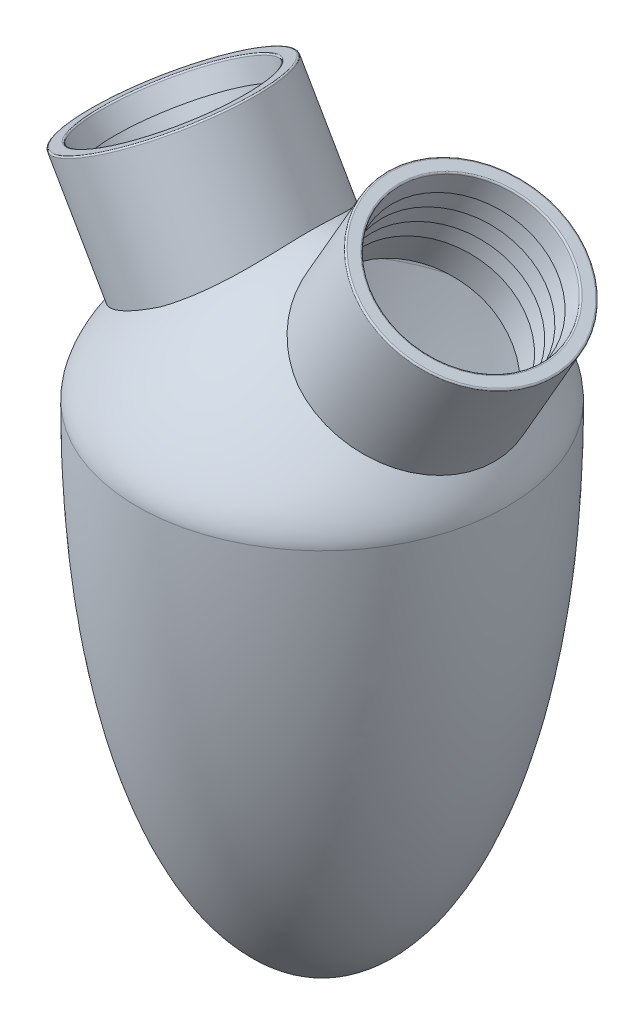
from build123d import *

# Parameters (mm, degrees)
SKETCH4_R                = 18.775
BOSS_EXTRUDE1_DEPTH      = 20
BOSS_EXTRUDE1_DEPTH_BACK = 3.5
SKETCH5_R                = 18.775
BOSS_EXTRUDE2_DEPTH      = 20
BOSS_EXTRUDE2_DEPTH_BACK = 3.5
SKETCH6_R                = 16.125
CUT_EXTRUDE1_DEPTH       = 24.3
SKETCH7_R                = 16.125
CUT_EXTRUDE2_DEPTH       = 24.3
FILLET1_R                = 0.3
LPATTERN1_COUNT          = 4
LPATTERN1_PITCH          = 4
LPATTERN2_COUNT          = 4
LPATTERN2_PITCH          = 4


with BuildPart() as part:
    # Sketch1 → Revolve1 (revolve)
    with BuildSketch(Plane.XY):
        with BuildLine():
            Line((0, 27.5), (0, 26.2))
            add(Edge.make_bspline(
                [(0, 26.2), (16.666666667, 26.2), (35, 7.333333333), (35, 0)],
                knots=[0, 0, 0, 0, 1, 1, 1, 1], degree=3))
            add(Edge.make_bspline(
                [(35, 0), (35, -62.333333333), (16.666666667, -93.4), (0, -93.4)],
                knots=[0, 0, 0, 0, 1, 1, 1, 1], degree=3))
            Line((0, -93.4), (0, -94.7))
            add(Edge.make_bspline(
                [(36.3, 0), (36.3, -63.333333333), (17.333333333, -94.7), (0, -94.7)],
                knots=[0, 0, 0, 0, 1, 1, 1, 1], degree=3))
            add(Edge.make_bspline(
                [(0, 27.5), (17, 27.5), (36.3, 7.666666667), (36.3, 0)],
                knots=[0, 0, 0, 0, 1, 1, 1, 1], degree=3))
        make_face()
    revolve(axis=Axis((0, 0, 0), (0, -1, 0)))

    # Sketch4 → Boss-Extrude1 (add, two sides)
    with BuildSketch(Plane(origin=(-12.990381057, 22.5, 0), x_dir=(0, 0, 1), z_dir=(-0.5, 0.866025404, 0))) as boss_extrude1_sk:
        with Locations((0, -7.323500512)):
            Circle(SKETCH4_R)
    extrude(amount=BOSS_EXTRUDE1_DEPTH)
    extrude(boss_extrude1_sk.sketch, amount=-BOSS_EXTRUDE1_DEPTH_BACK)

    # Sketch5 → Boss-Extrude2 (add, two sides)
    with BuildSketch(Plane(origin=(12.990381057, 22.5, 0), x_dir=(0, 0, 1), z_dir=(0.5, 0.866025404, 0))) as boss_extrude2_sk:
        with Locations((0, 7.312391534)):
            Circle(SKETCH5_R)
    extrude(amount=BOSS_EXTRUDE2_DEPTH)
    extrude(boss_extrude2_sk.sketch, amount=-BOSS_EXTRUDE2_DEPTH_BACK)

    # Sketch6 → Cut-Extrude1 (cut)
    with BuildSketch(Plane(origin=(-22.990381057, 39.820508076, 0), x_dir=(0.866025404, 0.5, 0), z_dir=(-0.5, 0.866025404, 0))):
        with Locations((-7.323500512, 0)):
            Circle(SKETCH6_R)
    extrude(amount=-CUT_EXTRUDE1_DEPTH, mode=Mode.SUBTRACT)

    # Sketch7 → Cut-Extrude2 (cut)
    with BuildSketch(Plane(origin=(22.990381057, 39.820508076, 0), x_dir=(0.866025404, -0.5, 0), z_dir=(0.5, 0.866025404, 0))):
        with Locations((7.312391534, 0)):
            Circle(SKETCH7_R)
    extrude(amount=-CUT_EXTRUDE2_DEPTH, mode=Mode.SUBTRACT)

    # Fillet1
    fillet1_edges = [part.edges().sort_by_distance(p)[0] for p in [
        (-29.332718545, 36.15875782, -18.775),
        (29.323097887, 36.164312309, -18.775),
        (-43.297378181, 28.09625782, 0),
        (15.358438251, 44.226812309, 0),
    ]]
    fillet(fillet1_edges, radius=FILLET1_R)

    # Sketch23 → Revolve2 (revolve)
    with BuildSketch(Plane(origin=(0, 0, 0), x_dir=(-0.866025404, 0.5, 0), z_dir=(0, 0, -1))):
        Polygon((-23.437391534, 45.680762114), (-23.437391534, 41.680762114), (-22.837391534, 41.680762114), align=None)
    revolve2 = revolve(axis=Axis((29.173097887, 35.904504688, 0), (-0.5, -0.866025404, 0)))

    # LPattern1: Revolve2 ×4
    with Locations(*[Vector(-0.5, -0.866025404, 0) * (i * LPATTERN1_PITCH) for i in range(1, LPATTERN1_COUNT)]):
        add(revolve2)

    # Sketch20 → Revolve3 (revolve)
    with BuildSketch(Plane(origin=(0, 0, 0), x_dir=(-0.866025404, -0.5, 0), z_dir=(0, 0, -1))):
        Polygon((-8.801499488, 45.680762114), (-8.801499488, 41.680762114), (-8.201499488, 41.680762114), align=None)
    revolve3 = revolve(axis=Axis((-29.182718545, 35.898950199, 0), (0.5, -0.866025404, 0)))

    # LPattern2: Revolve3 ×4
    with Locations(*[Vector(0.5, -0.866025404, 0) * (i * LPATTERN2_PITCH) for i in range(1, LPATTERN2_COUNT)]):
        add(revolve3)


solid = part.part
